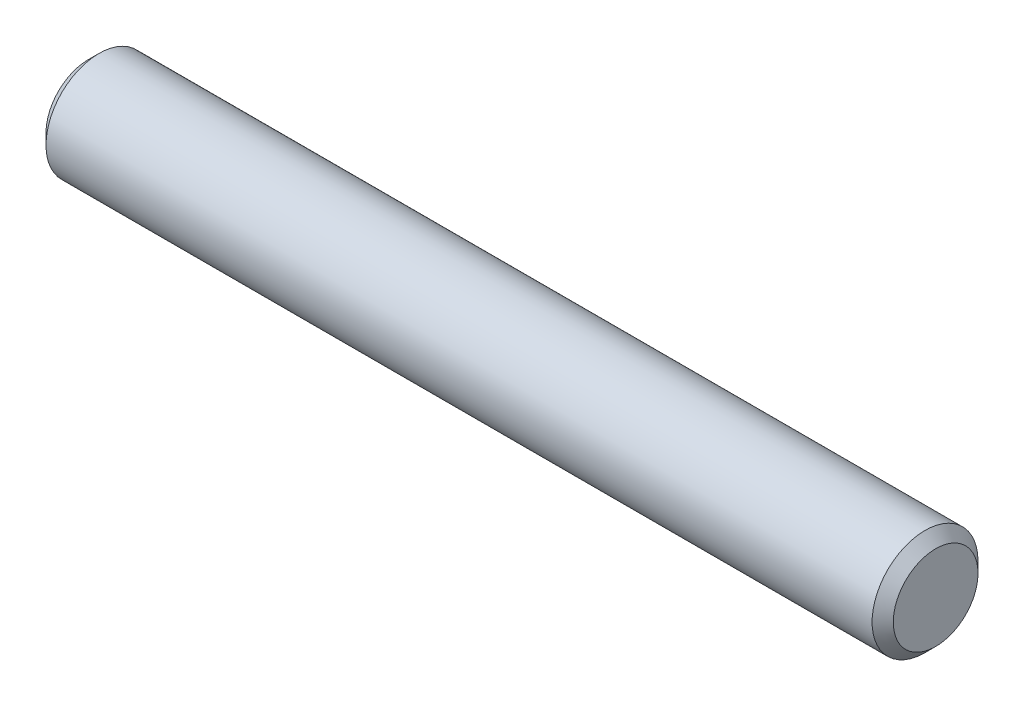
from build123d import *

# Parameters (mm, degrees)
SKETCH2_R           = 1.5875
EXTRUDE1_DEPTH      = 12.7
EXTRUDE1_DEPTH_BACK = 12.7
CHAMFER1_SIZE       = 0.3175


with BuildPart() as part:
    # Sketch2 → Extrude1 (new body, two sides)
    with BuildSketch(Plane(origin=(0, 0, 0), x_dir=(0, 0, -1), z_dir=(1, 0, 0))) as extrude1_sk:
        Circle(SKETCH2_R)
    extrude(amount=EXTRUDE1_DEPTH)
    extrude(extrude1_sk.sketch, amount=-EXTRUDE1_DEPTH_BACK)

    # Chamfer1
    chamfer1_edges = [part.edges().sort_by_distance(p)[0] for p in [
        (-12.7, 0, 1.5875),
        (12.7, 0, 1.5875),
    ]]
    chamfer(chamfer1_edges, length=CHAMFER1_SIZE)


solid = part.part
